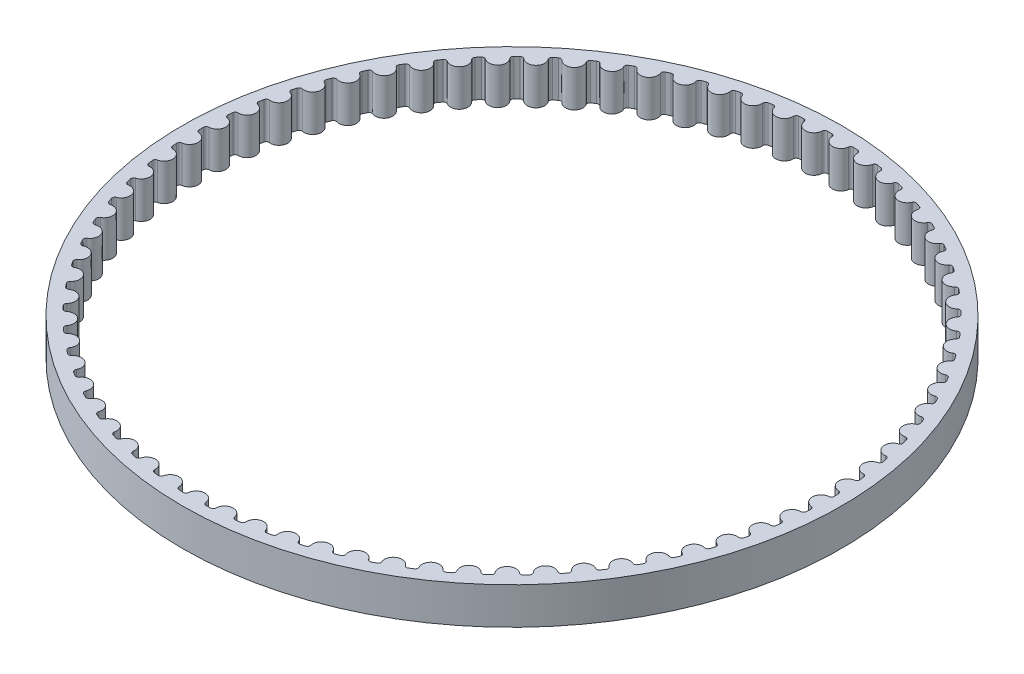
from build123d import *

# Parameters (mm, degrees)
SKETCH1_R           = 35.773932537
BOSS_EXTRUDE1_DEPTH = 4


with BuildPart() as part:
    # Sketch1 → Boss-Extrude1 (new body)
    with BuildSketch(Plane(origin=(0, 0, 0), x_dir=(1, 0, 0), z_dir=(0, 1, 0))):
        Circle(SKETCH1_R)
        with BuildLine():
            ThreePointArc((-1.718818178, -34.431057036), (-1.483145558, -34.442013644), (-1.247403475, -34.451357145))
            ThreePointArc((-1.247403475, -34.451357145), (-1.040649993, -34.378408388), (-0.939245232, -34.184023209))
            ThreePointArc((-0.939245232, -34.184023209), (0, -33.338941235), (0.939245232, -34.184023209))
            ThreePointArc((0.939245232, -34.184023209), (1.040649993, -34.378408388), (1.247403475, -34.451357145))
            ThreePointArc((1.247403475, -34.451357145), (1.483145558, -34.442013644), (1.718818178, -34.431057036))
            ThreePointArc((1.718818178, -34.431057036), (1.918535269, -34.340604802), (2.002854365, -34.138221962))
            ThreePointArc((2.002854365, -34.138221962), (2.865975373, -33.215526306), (3.874390986, -33.976737908))
            ThreePointArc((3.874390986, -33.976737908), (3.992130647, -34.161686267), (4.204389789, -34.216591459))
            ThreePointArc((4.204389789, -34.216591459), (4.438455984, -34.187017025), (4.672314302, -34.155841428))
            ThreePointArc((4.672314302, -34.155841428), (4.863516368, -34.048555392), (4.930125529, -33.839673264))
            ThreePointArc((4.930125529, -33.839673264), (5.710732068, -32.846195242), (6.780852104, -33.517900726))
            ThreePointArc((6.780852104, -33.517900726), (6.914054962, -33.692042973), (7.130248271, -33.728498101))
            ThreePointArc((7.130248271, -33.728498101), (7.360905634, -33.678911693), (7.591218246, -33.627747919))
            ThreePointArc((7.591218246, -33.627747919), (7.772489693, -33.50442239), (7.820895768, -33.290587465))
            ThreePointArc((7.820895768, -33.290587465), (8.5132085, -32.233682441), (9.637110166, -32.810908735))
            ThreePointArc((9.637110166, -32.810908735), (9.784790033, -32.972955581), (10.003316891, -32.990690744))
            ThreePointArc((10.003316891, -32.990690744), (10.228857715, -32.921459482), (10.453919466, -32.85068633))
            ThreePointArc((10.453919466, -32.85068633), (10.623918223, -32.712234367), (10.653762831, -32.495029803))
            ThreePointArc((10.653762831, -32.495029803), (11.252656115, -31.382522732), (12.422018436, -31.860996255))
            ThreePointArc((12.422018436, -31.860996255), (12.583081942, -32.009747961), (12.802324451, -32.008631855))
            ThreePointArc((12.802324451, -32.008631855), (13.021078911, -31.920268303), (13.239223523, -31.830409753))
            ThreePointArc((13.239223523, -31.830409753), (13.39669098, -31.677856407), (13.407753162, -31.45889031))
            ThreePointArc((13.407753162, -31.45889031), (13.908793001, -30.299017804), (15.114958427, -30.675196105))
            ThreePointArc((15.114958427, -30.675196105), (15.288213115, -30.809551367), (15.506548081, -30.789592254))
            ThreePointArc((15.506548081, -30.789592254), (15.716896595, -30.682750626), (15.926509002, -30.574471959))
            ThreePointArc((15.926509002, -30.574471959), (16.070279324, -30.40894668), (16.062477179, -30.189840199))
            ThreePointArc((16.062477179, -30.189840199), (16.46195405, -28.99118955), (17.695992554, -29.262287537))
            ThreePointArc((17.695992554, -29.262287537), (17.880155707, -29.381251634), (18.095966654, -29.342597285))
            ThreePointArc((18.095966654, -29.342597285), (18.296351876, -29.218068598), (18.49588018, -29.092171472))
            ThreePointArc((18.49588018, -29.092171472), (18.624888942, -28.914899751), (18.598280235, -28.697275074))
            ThreePointArc((18.598280235, -28.697275074), (18.893236551, -27.468720671), (20.146011744, -27.632731229))
            ThreePointArc((20.146011744, -27.632731229), (20.339719882, -27.735423394), (20.551409021, -27.678359991))
            ThreePointArc((20.551409021, -27.678359991), (20.740347368, -27.537066213), (20.928314333, -27.394482725))
            ThreePointArc((20.928314333, -27.394482725), (21.041606399, -27.206777021), (20.996388131, -26.992245364))
            ThreePointArc((20.996388131, -26.992245364), (21.184640138, -25.742882995), (22.446876912, -25.798591847))
            ThreePointArc((22.446876912, -25.798591847), (22.648695887, -25.884251782), (22.854695946, -25.809201804))
            ThreePointArc((22.854695946, -25.809201804), (23.030788585, -25.652189024), (23.205802568, -25.493974812))
            ThreePointArc((23.205802568, -25.493974812), (23.302539164, -25.297224833), (23.239046115, -25.087374514))
            ThreePointArc((23.239046115, -25.087374514), (23.319200062, -23.826454019), (24.581553256, -23.773448717))
            ThreePointArc((24.581553256, -23.773448717), (24.789988872, -23.841442227), (24.988774699, -23.748961317))
            ThreePointArc((24.988774699, -23.748961317), (25.150717902, -23.577392002), (25.31148316, -23.40471843))
            ThreePointArc((25.31148316, -23.40471843), (25.390948082, -23.200380842), (25.309650333, -22.99676552))
            ThreePointArc((25.309650333, -22.99676552), (25.281112787, -21.733622315), (26.53423638, -21.57229529))
            ThreePointArc((26.53423638, -21.57229529), (26.747745452, -21.622118974), (26.937845306, -21.512891829))
            ThreePointArc((26.937845306, -21.512891829), (27.084440102, -21.328036219), (27.229766387, -21.142181701))
            ThreePointArc((27.229766387, -21.142181701), (27.291371303, -20.931769349), (27.192870754, -20.73589652))
            ThreePointArc((27.192870754, -20.73589652), (27.055852998, -19.479882474), (28.290469302, -19.211428137))
            ThreePointArc((28.290469302, -19.211428137), (28.507471084, -19.242713118), (28.687477531, -19.117548417))
            ThreePointArc((28.687477531, -19.117548417), (28.817638584, -18.920775117), (28.94644995, -18.723115656))
            ThreePointArc((28.94644995, -18.723115656), (28.98973876, -18.50818636), (28.874764675, -18.321506197))
            ThreePointArc((28.874764675, -18.321506197), (28.630281139, -17.081920399), (29.837249487, -16.708326291))
            ThreePointArc((29.837249487, -16.708326291), (30.056137373, -16.720840946), (30.22471771, -16.580665365))
            ThreePointArc((30.22471771, -16.580665365), (30.337481352, -16.373431217), (30.448824125, -16.165430213))
            ThreePointArc((30.448824125, -16.165430213), (30.473476334, -15.947575233), (30.34287994, -15.771469852))
            ThreePointArc((30.34287994, -15.771469852), (29.992740696, -14.557489762), (31.163125115, -14.081521843))
            ThreePointArc((31.163125115, -14.081521843), (31.382278537, -14.075173517), (31.538184653, -13.921024867))
            ThreePointArc((31.538184653, -13.921024867), (31.632716022, -13.70486416), (31.72576586, -13.48806158))
            ThreePointArc((31.72576586, -13.48806158), (31.731598951, -13.26889384), (31.586347138, -13.104667063))
            ThreePointArc((31.586347138, -13.104667063), (31.133144495, -11.925280564), (32.258279869, -11.350462733))
            ThreePointArc((32.258279869, -11.350462733), (32.47607629, -11.325298429), (32.618153912, -11.158317972))
            ThreePointArc((32.618153912, -11.158317972), (32.69375313, -10.934831084), (32.767821123, -10.710832059))
            ThreePointArc((32.767821123, -10.710832059), (32.754791911, -10.491974199), (32.595960073, -10.340841903))
            ThreePointArc((32.595960073, -10.340841903), (32.043049383, -9.204780761), (33.114605604, -8.535368769))
            ThreePointArc((33.114605604, -8.535368769), (33.329432537, -8.491574793), (33.456629771, -8.312998795))
            ThreePointArc((33.456629771, -8.312998795), (33.512737129, -8.083840345), (33.567274904, -7.854303285))
            ThreePointArc((33.567274904, -7.854303285), (33.535479852, -7.637375651), (33.364243924, -7.500456768))
            ThreePointArc((33.364243924, -7.500456768), (32.715718746, -6.416131982), (33.725762386, -5.657081921))
            ThreePointArc((33.725762386, -5.657081921), (33.936029326, -5.594982509), (34.047404448, -5.406133083))
            ThreePointArc((34.047404448, -5.406133083), (34.083604547, -5.172999679), (34.118208326, -4.939623997))
            ThreePointArc((34.118208326, -4.939623997), (34.067882833, -4.726232647), (33.885510586, -4.604540875))
            ThreePointArc((33.885510586, -4.604540875), (33.146172372, -3.579980406), (34.087225422, -2.736912018))
            ThreePointArc((34.087225422, -2.736912018), (34.291375628, -2.656966931), (34.386104056, -2.459242253))
            ThreePointArc((34.386104056, -2.459242253), (34.402128881, -2.223859934), (34.41654247, -1.988373461))
            ThreePointArc((34.41654247, -1.988373461), (34.348059128, -1.780098269), (34.155900783, -1.674534573))
            ThreePointArc((34.155900783, -1.674534573), (33.331223336, -0.717323908), (34.196318567, 0.203521024))
            ThreePointArc((34.196318567, 0.203521024), (34.392840581, 0.3007199), (34.470220979, 0.505855946))
            ThreePointArc((34.470220979, 0.505855946), (34.46595189, 0.741744491), (34.460068574, 0.977598297))
            ThreePointArc((34.460068574, 0.977598297), (34.373934411, 1.179215333), (34.173412641, 1.267869398))
            ThreePointArc((34.173412641, 1.267869398), (33.269501583, 2.150643405), (34.052234134, 3.142447268))
            ThreePointArc((34.052234134, 3.142447268), (34.239672976, 3.256180306), (34.299132446, 3.467208965))
            ThreePointArc((34.299132446, 3.467208965), (34.274601049, 3.701857301), (34.248464388, 3.936332258))
            ThreePointArc((34.248464388, 3.936332258), (34.145317111, 4.129798438), (33.937916508, 4.200886507))
            ThreePointArc((33.937916508, 4.200886507), (32.961464081, 5.002688107), (33.656038873, 6.058107932))
            ThreePointArc((33.656038873, 6.058107932), (33.833006812, 6.187533092), (33.874105137, 6.402891982))
            ThreePointArc((33.874105137, 6.402891982), (33.829493054, 6.634562854), (33.783296554, 6.865922993))
            ThreePointArc((33.783296554, 6.865922993), (33.663899828, 7.04980596), (33.451155915, 7.102801722))
            ThreePointArc((33.451155915, 7.102801722), (32.409391431, 7.817694657), (33.010666076, 8.928916484))
            ThreePointArc((33.010666076, 8.928916484), (33.175852903, 9.073075549), (33.198285805, 9.291170226))
            ThreePointArc((33.198285805, 9.291170226), (33.133923329, 9.518148424), (33.068009011, 9.744680836))
            ThreePointArc((33.068009011, 9.744680836), (32.93324681, 9.917619185), (32.716734667, 9.952130279))
            ThreePointArc((32.716734667, 9.952130279), (31.617370985, 10.57482173), (32.120893856, 11.733618463))
            ThreePointArc((32.120893856, 11.733618463), (32.273076585, 11.891444128), (32.27667798, 12.110659897))
            ThreePointArc((32.27667798, 12.110659897), (32.193041627, 12.331264954), (32.1078975, 12.551292472))
            ThreePointArc((32.1078975, 12.551292472), (31.958767554, 12.712005827), (31.740090162, 12.727776744))
            ThreePointArc((31.740090162, 12.727776744), (30.591266587, 13.253656524), (30.993309777, 14.451448836))
            ThreePointArc((30.993309777, 14.451448836), (31.1313617, 14.621772615), (31.116104924, 14.840486479))
            ThreePointArc((31.116104924, 14.840486479), (31.013813909, 15.053085113), (30.910070349, 15.264978729))
            ThreePointArc((30.910070349, 15.264978729), (30.747676765, 15.412277226), (30.528453135, 15.409191204))
            ThreePointArc((30.528453135, 15.409191204), (29.338675154, 15.834365881), (29.636262075, 17.062285737))
            ThreePointArc((29.636262075, 17.062285737), (29.759161105, 17.243846614), (29.725159114, 17.460439291))
            ThreePointArc((29.725159114, 17.460439291), (29.604970763, 17.663457496), (29.483395852, 17.865648425))
            ThreePointArc((29.483395852, 17.865648425), (29.308940934, 17.998441517), (29.090794121, 17.976521403))
            ThreePointArc((29.090794121, 17.976521403), (27.868870435, 18.297843133), (28.059797858, 19.546799445))
            ThreePointArc((28.059797858, 19.546799445), (28.166634093, 19.738253205), (28.114138625, 19.95112112))
            ThreePointArc((28.114138625, 19.95112112), (27.976942771, 20.143055819), (27.838436607, 20.33404711))
            ThreePointArc((27.838436607, 20.33404711), (27.653211959, 20.451351643), (27.437757046, 20.410759727))
            ThreePointArc((27.437757046, 20.410759727), (26.19273435, 20.625849557), (26.275588714, 21.886595488))
            ThreePointArc((26.275588714, 21.886595488), (26.365571177, 22.086524676), (26.29497089, 22.294091829))
            ThreePointArc((26.29497089, 22.294091829), (26.141783284, 22.473522005), (25.987371317, 22.651899625))
            ThreePointArc((25.987371317, 22.651899625), (25.792748278, 22.752847118), (25.581580417, 22.693883928))
            ThreePointArc((25.581580417, 22.693883928), (24.322676423, 22.801149407), (24.296844305, 24.064350836))
            ThreePointArc((24.296844305, 24.064350836), (24.369306796, 24.271275245), (24.281124391, 24.472004881))
            ThreePointArc((24.281124391, 24.472004881), (24.113079179, 24.637602097), (23.943904622, 24.8020454))
            ThreePointArc((23.943904622, 24.8020454), (23.741324113, 24.885888473), (23.536006717, 24.808990551))
            ThreePointArc((23.536006717, 24.808990551), (22.27254191, 24.807637524), (22.138214562, 26.06394215))
            ThreePointArc((22.138214562, 26.06394215), (22.192620594, 26.276329784), (22.087508942, 26.468735771))
            ThreePointArc((22.087508942, 26.468735771), (21.905850273, 26.619274002), (21.723165635, 26.768565508))
            ThreePointArc((21.723165635, 26.768565508), (21.51412749, 26.834683416), (21.316180658, 26.740420089))
            ThreePointArc((21.316180658, 26.740420089), (20.057509289, 26.630458572), (19.815681223, 27.870565154))
            ThreePointArc((19.815681223, 27.870565154), (19.851627993, 28.08684357), (19.730365304, 28.269501403))
            ThreePointArc((19.730365304, 28.269501403), (19.536438115, 28.403866116), (19.341595929, 28.536900523))
            ThreePointArc((19.341595929, 28.536900523), (19.127647795, 28.584803752), (18.938537055, 28.473872911))
            ThreePointArc((18.938537055, 28.473872911), (17.693977887, 28.256117022), (17.346439513, 29.470844246))
            ThreePointArc((17.346439513, 29.470844246), (17.363660884, 29.689412194), (17.227144945, 29.860969536))
            ThreePointArc((17.227144945, 29.860969536), (17.022385005, 29.978165943), (16.816827815, 30.093958311))
            ThreePointArc((16.816827815, 30.093958311), (16.599553687, 30.123292202), (16.420679149, 29.996515141))
            ThreePointArc((16.420679149, 29.996515141), (15.199446463, 29.672577068), (14.748770835, 30.852931518))
            ThreePointArc((14.748770835, 30.852931518), (14.747139305, 31.072170797), (14.596380831, 31.231357499))
            ThreePointArc((14.596380831, 31.231357499), (14.382304111, 31.330517918), (14.16755379, 31.42821096))
            ThreePointArc((14.16755379, 31.42821096), (13.948562292, 31.438758336), (13.781248281, 31.297073668))
            ThreePointArc((13.781248281, 31.297073668), (12.592383656, 30.869351735), (12.041907417, 32.006594479))
            ThreePointArc((12.041907417, 32.006594479), (12.021435067, 32.224881918), (11.857550221, 32.370519417))
            ThreePointArc((11.857550221, 32.370519417), (11.63574167, 32.4509097), (11.413388155, 32.529780131))
            ThreePointArc((11.413388155, 32.529780131), (11.194300622, 32.521462902), (11.039785872, 32.365919611))
            ThreePointArc((11.039785872, 32.365919611), (9.892091245, 31.837580521), (9.245889929, 32.923291812))
            ThreePointArc((9.245889929, 32.923291812), (9.206728328, 33.139011289), (9.030930458, 33.270021335))
            ThreePointArc((9.030930458, 33.270021335), (8.803032269, 33.3310463), (8.574721786, 33.390510192))
            ThreePointArc((8.574721786, 33.390510192), (8.357160266, 33.363389936), (8.21658875, 33.195139609))
            ThreePointArc((8.21658875, 33.195139609), (7.118561252, 32.570095001), (6.381419108, 33.596236613))
            ThreePointArc((6.381419108, 33.596236613), (6.323858195, 33.807791014), (6.137448845, 33.923203655))
            ThreePointArc((6.137448845, 33.923203655), (5.905148297, 33.964411495), (5.672571178, 34.004028597))
            ThreePointArc((5.672571178, 34.004028597), (5.45814642, 33.958306103), (5.332558881, 33.778594407))
            ThreePointArc((5.332558881, 33.778594407), (4.292327922, 33.061471892), (3.469702492, 34.020446631))
            ThreePointArc((3.469702492, 34.020446631), (3.394168428, 34.226269683), (3.198527708, 34.325230445))
            ThreePointArc((3.198527708, 34.325230445), (2.963544672, 34.34631607), (2.728422837, 34.365793071))
            ThreePointArc((2.728422837, 34.365793071), (2.518722367, 34.301806853), (2.409048611, 34.111964311))
            ThreePointArc((2.409048611, 34.111964311), (1.434315698, 33.308073213), (0.532297413, 34.192781165))
            ThreePointArc((0.532297413, 34.192781165), (0.439349425, 34.391349026), (0.235925792, 34.473125237))
            ThreePointArc((0.235925792, 34.473125237), (0, 34.473932537), (-0.235925792, 34.473125237))
            ThreePointArc((-0.235925792, 34.473125237), (-0.439349425, 34.391349026), (-0.532297413, 34.192781165))
            ThreePointArc((-0.532297413, 34.192781165), (-1.434315698, 33.308073213), (-2.409048611, 34.111964311))
            ThreePointArc((-2.409048611, 34.111964311), (-2.518722367, 34.301806853), (-2.728422837, 34.365793071))
            ThreePointArc((-2.728422837, 34.365793071), (-2.963544672, 34.34631607), (-3.198527708, 34.325230445))
            ThreePointArc((-3.198527708, 34.325230445), (-3.394168428, 34.226269683), (-3.469702492, 34.020446631))
            ThreePointArc((-3.469702492, 34.020446631), (-4.292327922, 33.061471892), (-5.332558881, 33.778594407))
            ThreePointArc((-5.332558881, 33.778594407), (-5.45814642, 33.958306103), (-5.672571178, 34.004028597))
            ThreePointArc((-5.672571178, 34.004028597), (-5.905148297, 33.964411495), (-6.137448845, 33.923203655))
            ThreePointArc((-6.137448845, 33.923203655), (-6.323858195, 33.807791014), (-6.381419108, 33.596236613))
            ThreePointArc((-6.381419108, 33.596236613), (-7.118561252, 32.570095001), (-8.21658875, 33.195139609))
            ThreePointArc((-8.21658875, 33.195139609), (-8.357160266, 33.363389936), (-8.574721786, 33.390510192))
            ThreePointArc((-8.574721786, 33.390510192), (-8.803032269, 33.3310463), (-9.030930458, 33.270021335))
            ThreePointArc((-9.030930458, 33.270021335), (-9.206728328, 33.139011289), (-9.245889929, 32.923291812))
            ThreePointArc((-9.245889929, 32.923291812), (-9.892091245, 31.837580521), (-11.039785872, 32.365919611))
            ThreePointArc((-11.039785872, 32.365919611), (-11.194300622, 32.521462902), (-11.413388155, 32.529780131))
            ThreePointArc((-11.413388155, 32.529780131), (-11.63574167, 32.4509097), (-11.857550221, 32.370519417))
            ThreePointArc((-11.857550221, 32.370519417), (-12.021435067, 32.224881918), (-12.041907417, 32.006594479))
            ThreePointArc((-12.041907417, 32.006594479), (-12.592383656, 30.869351735), (-13.781248281, 31.297073668))
            ThreePointArc((-13.781248281, 31.297073668), (-13.948562292, 31.438758336), (-14.16755379, 31.42821096))
            ThreePointArc((-14.16755379, 31.42821096), (-14.382304111, 31.330517918), (-14.596380831, 31.231357499))
            ThreePointArc((-14.596380831, 31.231357499), (-14.747139305, 31.072170797), (-14.748770835, 30.852931518))
            ThreePointArc((-14.748770835, 30.852931518), (-15.199446463, 29.672577068), (-16.420679149, 29.996515141))
            ThreePointArc((-16.420679149, 29.996515141), (-16.599553687, 30.123292202), (-16.816827815, 30.093958311))
            ThreePointArc((-16.816827815, 30.093958311), (-17.022385005, 29.978165943), (-17.227144945, 29.860969536))
            ThreePointArc((-17.227144945, 29.860969536), (-17.363660884, 29.689412194), (-17.346439513, 29.470844246))
            ThreePointArc((-17.346439513, 29.470844246), (-17.693977887, 28.256117022), (-18.938537055, 28.473872911))
            ThreePointArc((-18.938537055, 28.473872911), (-19.127647795, 28.584803752), (-19.341595929, 28.536900523))
            ThreePointArc((-19.341595929, 28.536900523), (-19.536438115, 28.403866116), (-19.730365304, 28.269501403))
            ThreePointArc((-19.730365304, 28.269501403), (-19.851627993, 28.08684357), (-19.815681223, 27.870565154))
            ThreePointArc((-19.815681223, 27.870565154), (-20.057509289, 26.630458572), (-21.316180658, 26.740420089))
            ThreePointArc((-21.316180658, 26.740420089), (-21.51412749, 26.834683416), (-21.723165635, 26.768565508))
            ThreePointArc((-21.723165635, 26.768565508), (-21.905850273, 26.619274002), (-22.087508942, 26.468735771))
            ThreePointArc((-22.087508942, 26.468735771), (-22.192620594, 26.276329784), (-22.138214562, 26.06394215))
            ThreePointArc((-22.138214562, 26.06394215), (-22.27254191, 24.807637524), (-23.536006717, 24.808990551))
            ThreePointArc((-23.536006717, 24.808990551), (-23.741324113, 24.885888473), (-23.943904622, 24.8020454))
            ThreePointArc((-23.943904622, 24.8020454), (-24.113079179, 24.637602097), (-24.281124391, 24.472004881))
            ThreePointArc((-24.281124391, 24.472004881), (-24.369306796, 24.271275245), (-24.296844305, 24.064350836))
            ThreePointArc((-24.296844305, 24.064350836), (-24.322676423, 22.801149407), (-25.581580417, 22.693883928))
            ThreePointArc((-25.581580417, 22.693883928), (-25.792748278, 22.752847118), (-25.987371317, 22.651899625))
            ThreePointArc((-25.987371317, 22.651899625), (-26.141783284, 22.473522005), (-26.29497089, 22.294091829))
            ThreePointArc((-26.29497089, 22.294091829), (-26.365571177, 22.086524676), (-26.275588714, 21.886595488))
            ThreePointArc((-26.275588714, 21.886595488), (-26.19273435, 20.625849557), (-27.437757046, 20.410759727))
            ThreePointArc((-27.437757046, 20.410759727), (-27.653211959, 20.451351643), (-27.838436607, 20.33404711))
            ThreePointArc((-27.838436607, 20.33404711), (-27.976942771, 20.143055819), (-28.114138625, 19.95112112))
            ThreePointArc((-28.114138625, 19.95112112), (-28.166634093, 19.738253205), (-28.059797858, 19.546799445))
            ThreePointArc((-28.059797858, 19.546799445), (-27.868870435, 18.297843133), (-29.090794121, 17.976521403))
            ThreePointArc((-29.090794121, 17.976521403), (-29.308940934, 17.998441517), (-29.483395852, 17.865648425))
            ThreePointArc((-29.483395852, 17.865648425), (-29.604970763, 17.663457496), (-29.725159114, 17.460439291))
            ThreePointArc((-29.725159114, 17.460439291), (-29.759161105, 17.243846614), (-29.636262075, 17.062285737))
            ThreePointArc((-29.636262075, 17.062285737), (-29.338675154, 15.834365881), (-30.528453135, 15.409191204))
            ThreePointArc((-30.528453135, 15.409191204), (-30.747676765, 15.412277226), (-30.910070349, 15.264978729))
            ThreePointArc((-30.910070349, 15.264978729), (-31.013813909, 15.053085113), (-31.116104924, 14.840486479))
            ThreePointArc((-31.116104924, 14.840486479), (-31.1313617, 14.621772615), (-30.993309777, 14.451448836))
            ThreePointArc((-30.993309777, 14.451448836), (-30.591266587, 13.253656524), (-31.740090162, 12.727776744))
            ThreePointArc((-31.740090162, 12.727776744), (-31.958767554, 12.712005827), (-32.1078975, 12.551292472))
            ThreePointArc((-32.1078975, 12.551292472), (-32.193041627, 12.331264954), (-32.27667798, 12.110659897))
            ThreePointArc((-32.27667798, 12.110659897), (-32.273076585, 11.891444128), (-32.120893856, 11.733618463))
            ThreePointArc((-32.120893856, 11.733618463), (-31.617370985, 10.57482173), (-32.716734667, 9.952130279))
            ThreePointArc((-32.716734667, 9.952130279), (-32.93324681, 9.917619185), (-33.068009011, 9.744680836))
            ThreePointArc((-33.068009011, 9.744680836), (-33.133923329, 9.518148424), (-33.198285805, 9.291170226))
            ThreePointArc((-33.198285805, 9.291170226), (-33.175852903, 9.073075549), (-33.010666076, 8.928916484))
            ThreePointArc((-33.010666076, 8.928916484), (-32.409391431, 7.817694657), (-33.451155915, 7.102801722))
            ThreePointArc((-33.451155915, 7.102801722), (-33.663899828, 7.04980596), (-33.783296554, 6.865922993))
            ThreePointArc((-33.783296554, 6.865922993), (-33.829493054, 6.634562854), (-33.874105137, 6.402891982))
            ThreePointArc((-33.874105137, 6.402891982), (-33.833006812, 6.187533092), (-33.656038873, 6.058107932))
            ThreePointArc((-33.656038873, 6.058107932), (-32.961464081, 5.002688107), (-33.937916508, 4.200886507))
            ThreePointArc((-33.937916508, 4.200886507), (-34.145317111, 4.129798438), (-34.248464388, 3.936332258))
            ThreePointArc((-34.248464388, 3.936332258), (-34.274601049, 3.701857301), (-34.299132446, 3.467208965))
            ThreePointArc((-34.299132446, 3.467208965), (-34.239672976, 3.256180306), (-34.052234134, 3.142447268))
            ThreePointArc((-34.052234134, 3.142447268), (-33.269501583, 2.150643405), (-34.173412641, 1.267869398))
            ThreePointArc((-34.173412641, 1.267869398), (-34.373934411, 1.179215333), (-34.460068574, 0.977598297))
            ThreePointArc((-34.460068574, 0.977598297), (-34.46595189, 0.741744491), (-34.470220979, 0.505855946))
            ThreePointArc((-34.470220979, 0.505855946), (-34.392840581, 0.3007199), (-34.196318567, 0.203521024))
            ThreePointArc((-34.196318567, 0.203521024), (-33.331223336, -0.717323908), (-34.155900783, -1.674534573))
            ThreePointArc((-34.155900783, -1.674534573), (-34.348059128, -1.780098269), (-34.41654247, -1.988373461))
            ThreePointArc((-34.41654247, -1.988373461), (-34.402128881, -2.223859934), (-34.386104056, -2.459242253))
            ThreePointArc((-34.386104056, -2.459242253), (-34.291375628, -2.656966931), (-34.087225422, -2.736912018))
            ThreePointArc((-34.087225422, -2.736912018), (-33.146172372, -3.579980406), (-33.885510586, -4.604540875))
            ThreePointArc((-33.885510586, -4.604540875), (-34.067882833, -4.726232647), (-34.118208326, -4.939623997))
            ThreePointArc((-34.118208326, -4.939623997), (-34.083604547, -5.172999679), (-34.047404448, -5.406133083))
            ThreePointArc((-34.047404448, -5.406133083), (-33.936029326, -5.594982509), (-33.725762386, -5.657081921))
            ThreePointArc((-33.725762386, -5.657081921), (-32.715718746, -6.416131982), (-33.364243924, -7.500456768))
            ThreePointArc((-33.364243924, -7.500456768), (-33.535479852, -7.637375651), (-33.567274904, -7.854303285))
            ThreePointArc((-33.567274904, -7.854303285), (-33.512737129, -8.083840345), (-33.456629771, -8.312998795))
            ThreePointArc((-33.456629771, -8.312998795), (-33.329432537, -8.491574793), (-33.114605604, -8.535368769))
            ThreePointArc((-33.114605604, -8.535368769), (-32.043049383, -9.204780761), (-32.595960073, -10.340841903))
            ThreePointArc((-32.595960073, -10.340841903), (-32.754791911, -10.491974199), (-32.767821123, -10.710832059))
            ThreePointArc((-32.767821123, -10.710832059), (-32.69375313, -10.934831084), (-32.618153912, -11.158317972))
            ThreePointArc((-32.618153912, -11.158317972), (-32.47607629, -11.325298429), (-32.258279869, -11.350462733))
            ThreePointArc((-32.258279869, -11.350462733), (-31.133144495, -11.925280564), (-31.586347138, -13.104667063))
            ThreePointArc((-31.586347138, -13.104667063), (-31.731598951, -13.26889384), (-31.72576586, -13.48806158))
            ThreePointArc((-31.72576586, -13.48806158), (-31.632716022, -13.70486416), (-31.538184653, -13.921024867))
            ThreePointArc((-31.538184653, -13.921024867), (-31.382278537, -14.075173517), (-31.163125115, -14.081521843))
            ThreePointArc((-31.163125115, -14.081521843), (-29.992740696, -14.557489762), (-30.34287994, -15.771469852))
            ThreePointArc((-30.34287994, -15.771469852), (-30.473476334, -15.947575233), (-30.448824125, -16.165430213))
            ThreePointArc((-30.448824125, -16.165430213), (-30.337481352, -16.373431217), (-30.22471771, -16.580665365))
            ThreePointArc((-30.22471771, -16.580665365), (-30.056137373, -16.720840946), (-29.837249487, -16.708326291))
            ThreePointArc((-29.837249487, -16.708326291), (-28.630281139, -17.081920399), (-28.874764675, -18.321506197))
            ThreePointArc((-28.874764675, -18.321506197), (-28.98973876, -18.50818636), (-28.94644995, -18.723115656))
            ThreePointArc((-28.94644995, -18.723115656), (-28.817638584, -18.920775117), (-28.687477531, -19.117548417))
            ThreePointArc((-28.687477531, -19.117548417), (-28.507471084, -19.242713118), (-28.290469302, -19.211428137))
            ThreePointArc((-28.290469302, -19.211428137), (-27.055852998, -19.479882474), (-27.192870754, -20.73589652))
            ThreePointArc((-27.192870754, -20.73589652), (-27.291371303, -20.931769349), (-27.229766387, -21.142181701))
            ThreePointArc((-27.229766387, -21.142181701), (-27.084440102, -21.328036219), (-26.937845306, -21.512891829))
            ThreePointArc((-26.937845306, -21.512891829), (-26.747745452, -21.622118974), (-26.53423638, -21.57229529))
            ThreePointArc((-26.53423638, -21.57229529), (-25.281112787, -21.733622315), (-25.309650333, -22.99676552))
            ThreePointArc((-25.309650333, -22.99676552), (-25.390948082, -23.200380842), (-25.31148316, -23.40471843))
            ThreePointArc((-25.31148316, -23.40471843), (-25.150717902, -23.577392002), (-24.988774699, -23.748961317))
            ThreePointArc((-24.988774699, -23.748961317), (-24.789988872, -23.841442227), (-24.581553256, -23.773448717))
            ThreePointArc((-24.581553256, -23.773448717), (-23.319200062, -23.826454019), (-23.239046115, -25.087374514))
            ThreePointArc((-23.239046115, -25.087374514), (-23.302539164, -25.297224833), (-23.205802568, -25.493974812))
            ThreePointArc((-23.205802568, -25.493974812), (-23.030788585, -25.652189024), (-22.854695946, -25.809201804))
            ThreePointArc((-22.854695946, -25.809201804), (-22.648695887, -25.884251782), (-22.446876912, -25.798591847))
            ThreePointArc((-22.446876912, -25.798591847), (-21.184640138, -25.742882995), (-20.996388131, -26.992245364))
            ThreePointArc((-20.996388131, -26.992245364), (-21.041606399, -27.206777021), (-20.928314333, -27.394482725))
            ThreePointArc((-20.928314333, -27.394482725), (-20.740347368, -27.537066213), (-20.551409021, -27.678359991))
            ThreePointArc((-20.551409021, -27.678359991), (-20.339719882, -27.735423394), (-20.146011744, -27.632731229))
            ThreePointArc((-20.146011744, -27.632731229), (-18.893236551, -27.468720671), (-18.598280235, -28.697275074))
            ThreePointArc((-18.598280235, -28.697275074), (-18.624888942, -28.914899751), (-18.49588018, -29.092171472))
            ThreePointArc((-18.49588018, -29.092171472), (-18.296351876, -29.218068598), (-18.095966654, -29.342597285))
            ThreePointArc((-18.095966654, -29.342597285), (-17.880155707, -29.381251634), (-17.695992554, -29.262287537))
            ThreePointArc((-17.695992554, -29.262287537), (-16.46195405, -28.99118955), (-16.062477179, -30.189840199))
            ThreePointArc((-16.062477179, -30.189840199), (-16.070279324, -30.40894668), (-15.926509002, -30.574471959))
            ThreePointArc((-15.926509002, -30.574471959), (-15.716896595, -30.682750626), (-15.506548081, -30.789592254))
            ThreePointArc((-15.506548081, -30.789592254), (-15.288213115, -30.809551367), (-15.114958427, -30.675196105))
            ThreePointArc((-15.114958427, -30.675196105), (-13.908793001, -30.299017804), (-13.407753162, -31.45889031))
            ThreePointArc((-13.407753162, -31.45889031), (-13.39669098, -31.677856407), (-13.239223523, -31.830409753))
            ThreePointArc((-13.239223523, -31.830409753), (-13.021078911, -31.920268303), (-12.802324451, -32.008631855))
            ThreePointArc((-12.802324451, -32.008631855), (-12.583081942, -32.009747961), (-12.422018436, -31.860996255))
            ThreePointArc((-12.422018436, -31.860996255), (-11.252656115, -31.382522732), (-10.653762831, -32.495029803))
            ThreePointArc((-10.653762831, -32.495029803), (-10.623918223, -32.712234367), (-10.453919466, -32.85068633))
            ThreePointArc((-10.453919466, -32.85068633), (-10.228857715, -32.921459482), (-10.003316891, -32.990690744))
            ThreePointArc((-10.003316891, -32.990690744), (-9.784790033, -32.972955581), (-9.637110166, -32.810908735))
            ThreePointArc((-9.637110166, -32.810908735), (-8.5132085, -32.233682441), (-7.820895768, -33.290587465))
            ThreePointArc((-7.820895768, -33.290587465), (-7.772489693, -33.50442239), (-7.591218246, -33.627747919))
            ThreePointArc((-7.591218246, -33.627747919), (-7.360905634, -33.678911693), (-7.130248271, -33.728498101))
            ThreePointArc((-7.130248271, -33.728498101), (-6.914054962, -33.692042973), (-6.780852104, -33.517900726))
            ThreePointArc((-6.780852104, -33.517900726), (-5.710732068, -32.846195242), (-4.930125529, -33.839673264))
            ThreePointArc((-4.930125529, -33.839673264), (-4.863516368, -34.048555392), (-4.672314302, -34.155841428))
            ThreePointArc((-4.672314302, -34.155841428), (-4.438455984, -34.187017025), (-4.204389789, -34.216591459))
            ThreePointArc((-4.204389789, -34.216591459), (-3.992130647, -34.161686267), (-3.874390986, -33.976737908))
            ThreePointArc((-3.874390986, -33.976737908), (-2.865975373, -33.215526306), (-2.002854365, -34.138221962))
            ThreePointArc((-2.002854365, -34.138221962), (-1.918535269, -34.340604802), (-1.718818178, -34.431057036))
        make_face(mode=Mode.SUBTRACT)
    extrude(amount=BOSS_EXTRUDE1_DEPTH)


solid = part.part
